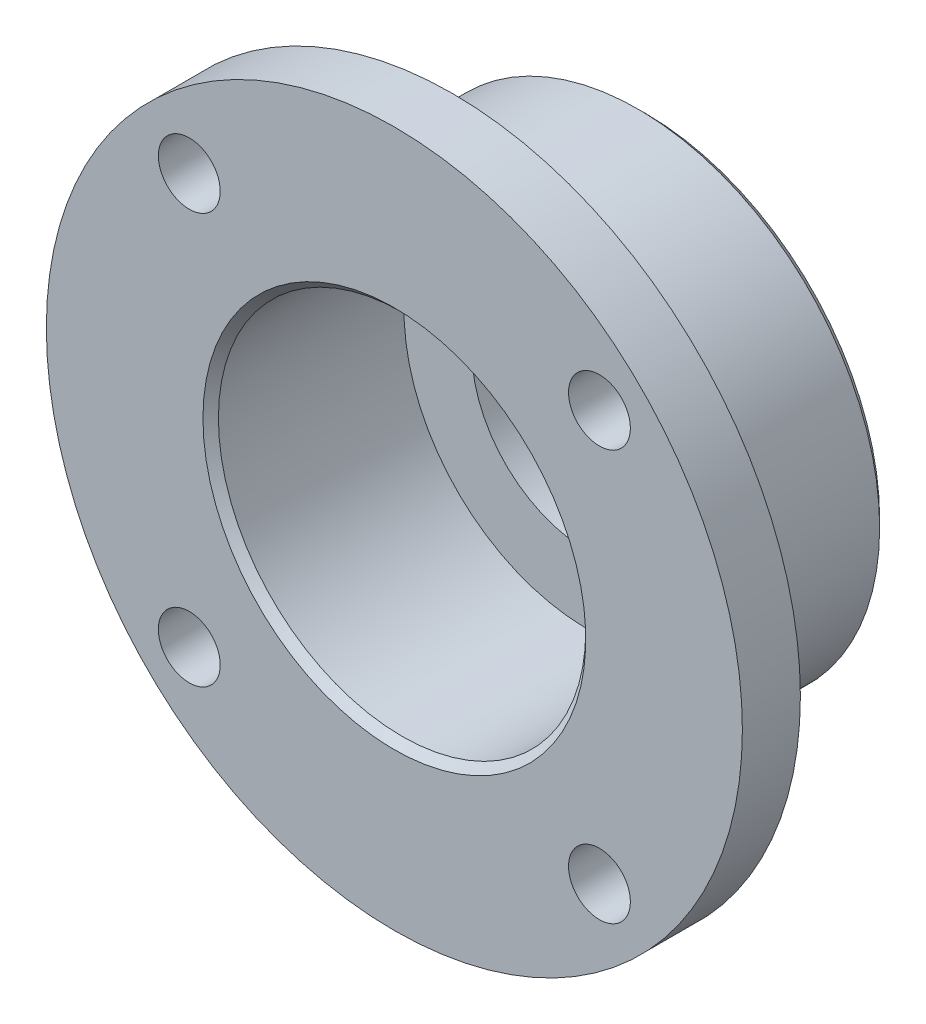
from build123d import *

# Parameters (mm, degrees)
SKETCH_2_R               = 1.6
CUT_EXTRUDE_1_DEPTH      = 3
PATTERN_CIRCULAR_1_COUNT = 4
CHAMFER_1_SIZE           = 0.4


with BuildPart() as part:
    # Эскиз1 → Повернуть1 (revolve)
    with BuildSketch(Plane(origin=(0, 0, 0), x_dir=(1, 0, 0), z_dir=(0, 1, 0))):
        Polygon((-18, 0), (-18, 3), (-12.5, 3), (-12.5, 13), (-6, 13), (-6, 10), (-9.5, 10), (-9.5, 0), align=None)
    revolve(axis=Axis((0, 0, 0), (0, 0, -1)))

    # Эскиз2 → Вырез-Вытянуть1 (cut)
    with BuildSketch(Plane.XY):
        with Locations((10.606601718, 10.606601718)):
            Circle(SKETCH_2_R)
    cut_extrude_1 = extrude(amount=-CUT_EXTRUDE_1_DEPTH, mode=Mode.SUBTRACT)

    # Круговой массив1: Вырез-Вытянуть1 ×4 about axis
    pattern_circular_1_axis = Axis((0, 0, 0), (0, 0, 1))
    for i in range(1, PATTERN_CIRCULAR_1_COUNT):
        add(cut_extrude_1.rotate(pattern_circular_1_axis, i * 360 / PATTERN_CIRCULAR_1_COUNT), mode=Mode.SUBTRACT)

    # Фаска1
    chamfer_1_edges = [part.edges().sort_by_distance(p)[0] for p in [
        (9.5, 0, 0),
        (12.5, 0, -13),
    ]]
    chamfer(chamfer_1_edges, length=CHAMFER_1_SIZE)


solid = part.part
